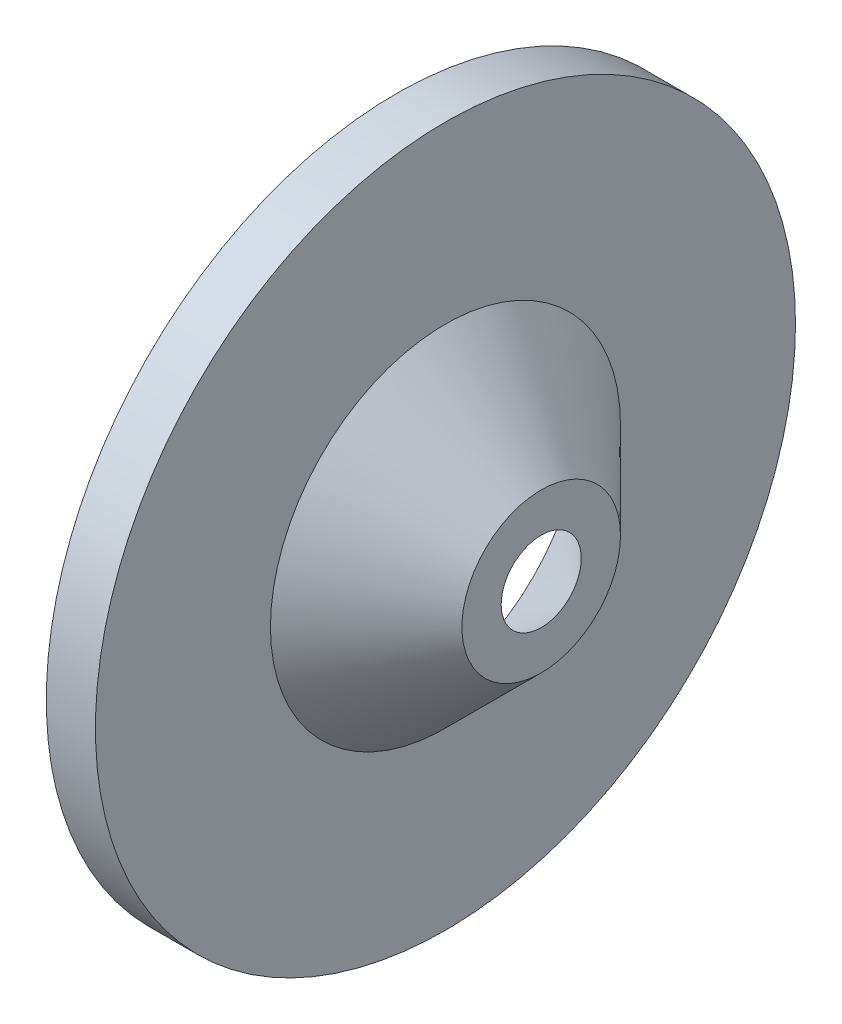
from build123d import *

# Parameters (mm, degrees)
VACIADO1_T = -10


with BuildPart() as part:
    # Croquis1 → Revolución1 (revolve)
    with BuildSketch(Plane.XY, mode=Mode.PRIVATE) as revoluci_n1_sk:
        Polygon((0, 53.427911052), (0, -72.710427761), (17.703234608, -72.710427761), (17.703234608, -9.641258354), (52.203454236, 24.858961274), (52.203454236, 53.427911052), align=None)
    revolve(revoluci_n1_sk.sketch.rotate(Axis((52.203454236, 53.427911052, 0), (-1, 0, 0)), 270), axis=Axis((52.203454236, 53.427911052, 0), (-1, 0, 0)))

    # Vaciado1
    vaciado1_openings = [part.faces().sort_by_distance(p)[0] for p in [
        (52.203454236, 53.427911052, 0),
        (0, 53.427911052, 0),
    ]]
    offset(amount=VACIADO1_T, openings=vaciado1_openings, kind=Kind.INTERSECTION)


solid = part.part
